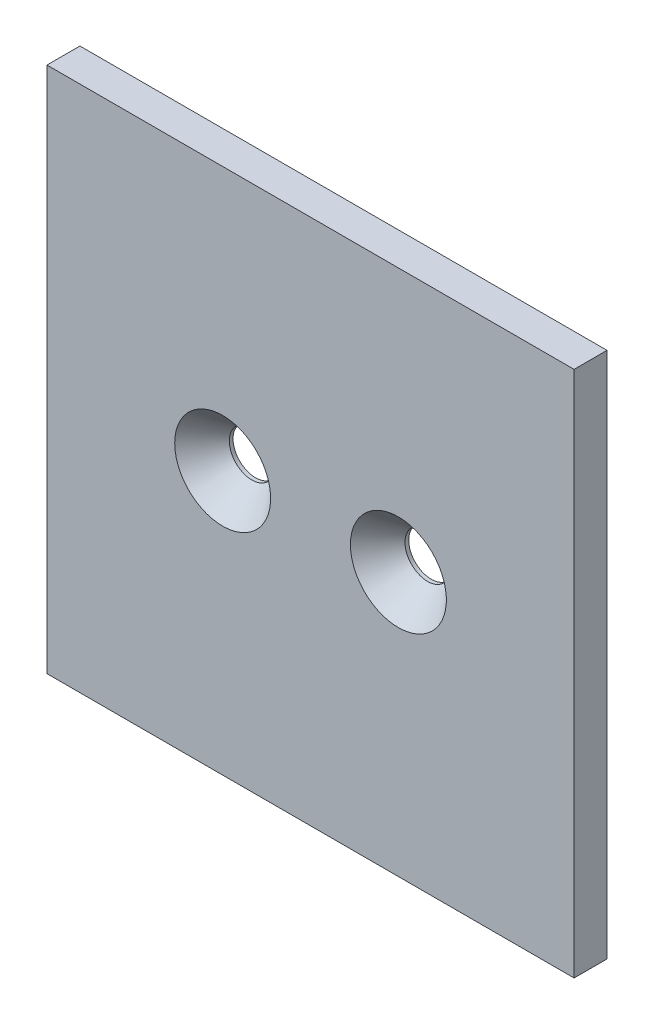
from build123d import *

# Parameters (mm, degrees)
SKETCH1_W           = 76.2
SKETCH1_H           = 76.2
SKETCH1_R           = 3.2639
BOSS_EXTRUDE1_DEPTH = 2.38125


with BuildPart() as part:
    # Sketch1 → Boss-Extrude1 (new, symmetric)
    with BuildSketch(Plane.XY):
        Rectangle(SKETCH1_W, SKETCH1_H)
        with Locations(Location((-12.7, 0, 0), (0, 0, 180))):
            Circle(SKETCH1_R, mode=Mode.SUBTRACT)
        with Locations(Location((12.7, 0, 0), (0, 0, 180))):
            Circle(SKETCH1_R, mode=Mode.SUBTRACT)
    extrude(amount=BOSS_EXTRUDE1_DEPTH, both=True)

    # Sketch2 → Cut-Revolve1 (revolve, cut)
    with BuildSketch(Plane(origin=(0, 0, 0), x_dir=(1, 0, 0), z_dir=(0, 1, 0)), mode=Mode.PRIVATE) as cut_revolve1_sk:
        Polygon((-5.7658, -2.38125), (-12.7, 5.595634609), (-12.7, -2.38125), align=None)
    cut_revolve1 = revolve(cut_revolve1_sk.sketch.rotate(Axis((-12.7, 0, -5.595634609), (0, 0, 1)), 180), axis=Axis((-12.7, 0, -5.595634609), (0, 0, 1)), mode=Mode.SUBTRACT)

    # Sketch-Pattern1: Cut-Revolve1 at 1 more place
    with Locations((25.4, 0, 0)):
        add(cut_revolve1, mode=Mode.SUBTRACT)


solid = part.part
